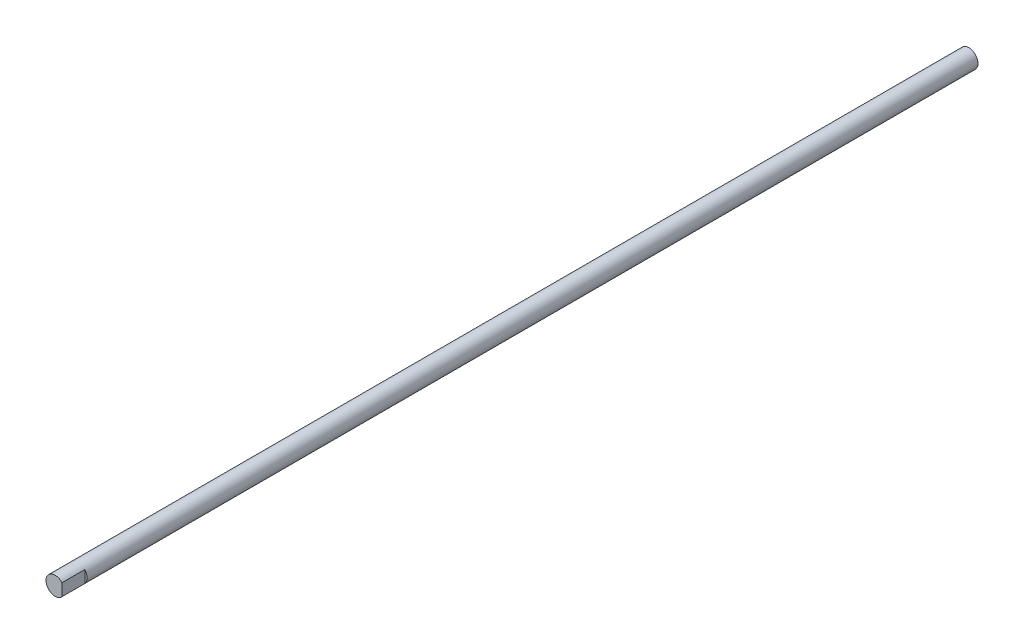
from build123d import *

# Parameters (mm, degrees)
CROQUIS1_R              = 4
SALIENTE_EXTRUIR1_DEPTH = 400
CROQUIS4_W              = 1
CROQUIS4_H              = 8
CORTAR_EXTRUIR1_DEPTH   = 10


with BuildPart() as part:
    # Croquis1 → Saliente-Extruir1 (new body)
    with BuildSketch(Plane.XY):
        Circle(CROQUIS1_R)
    extrude(amount=SALIENTE_EXTRUIR1_DEPTH)

    # Croquis4 → Cortar-Extruir1 (cut)
    with BuildSketch(Plane.XY.offset(400)):
        with Locations((3.5, 0)):
            Rectangle(CROQUIS4_W, CROQUIS4_H)
    extrude(amount=-CORTAR_EXTRUIR1_DEPTH, mode=Mode.SUBTRACT)


solid = part.part
